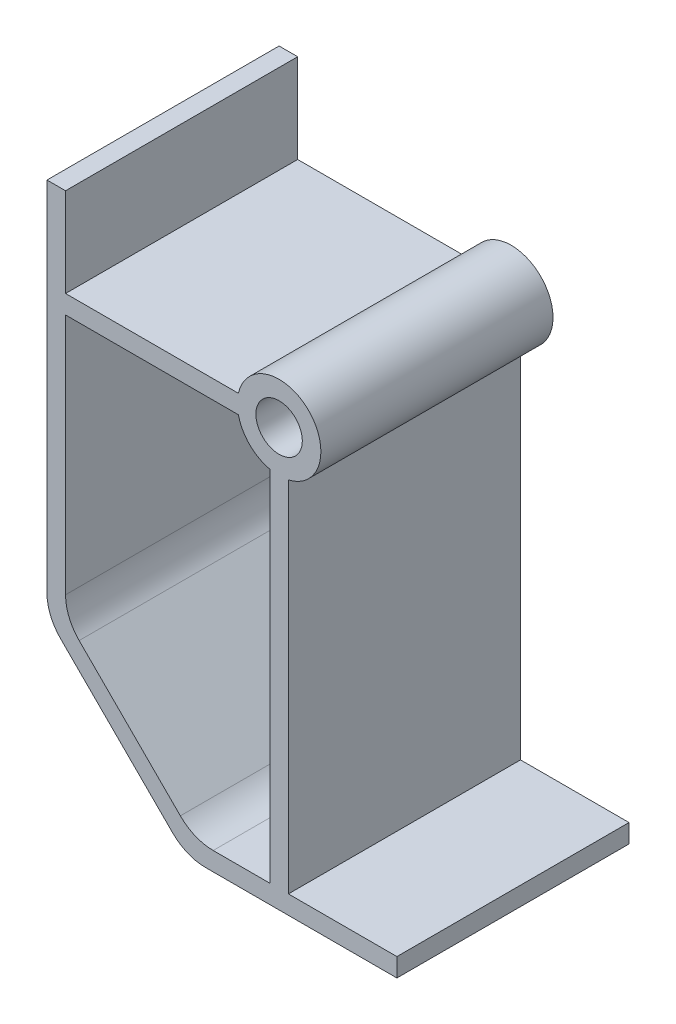
from build123d import *

# Parameters (mm, degrees)
SKETCH1_R           = 2.5
BOSS_EXTRUDE1_DEPTH = 25
FILLET1_R           = 5


with BuildPart() as part:
    # Sketch1 → Boss-Extrude1 (new body)
    with BuildSketch(Plane.XY):
        with BuildLine():
            Line((-25, 10.583953595), (-25, -30))
            Line((-25, -30), (-10, -45))
            Line((-10, -45), (12.687018602, -45))
            Line((12.687018602, -45), (12.687018602, -43))
            Line((12.687018602, -43), (1, -43))
            Line((1, -43), (1, -4.387482194))
            ThreePointArc((1, -4.387482194), (3.181980515, 3.181980515), (-4.387482194, 1))
            Line((-4.387482194, 1), (-23, 1))
            Line((-23, 1), (-23, 10.583953595))
            Line((-23, 10.583953595), (-25, 10.583953595))
        make_face()
        Circle(SKETCH1_R, mode=Mode.SUBTRACT)
        with BuildLine():
            Line((-23, -29.171572875), (-9.171572875, -43))
            Line((-9.171572875, -43), (-1, -43))
            Line((-1, -43), (-1, -4.387482194))
            ThreePointArc((-1, -4.387482194), (-3.181980515, -3.181980515), (-4.387482194, -1))
            Line((-4.387482194, -1), (-23, -1))
            Line((-23, -1), (-23, -29.171572875))
        make_face(mode=Mode.SUBTRACT)
    extrude(amount=BOSS_EXTRUDE1_DEPTH)

    # Fillet1
    fillet1_edges = [part.edges().sort_by_distance(p)[0] for p in [
        (-10, -45, 12.5),
        (-25, -30, 12.5),
        (-23, -29.171572875, 12.5),
        (-9.171572875, -43, 12.5),
    ]]
    fillet(fillet1_edges, radius=FILLET1_R)


solid = part.part
